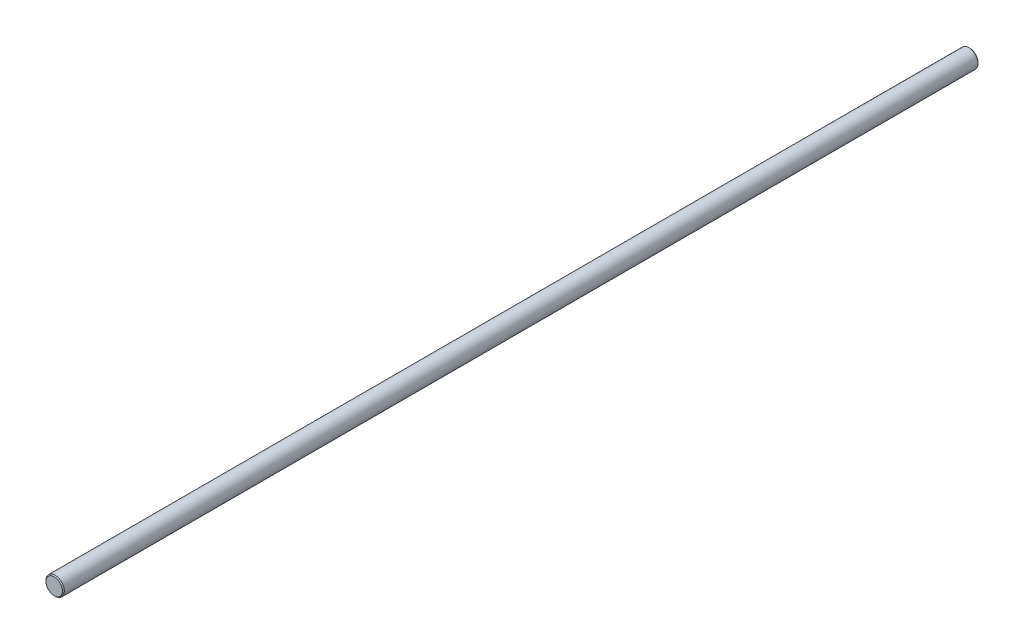
from build123d import *

# Parameters (mm, degrees)
SKETCH1_R           = 10
BOSS_EXTRUDE1_DEPTH = 1000
CHAMFER1_SIZE       = 1
SKETCH2_R           = 3
CUT_EXTRUDE1_DEPTH  = 10
LPATTERN1_COUNT     = 7
LPATTERN1_PITCH     = 150


with BuildPart() as part:
    # Sketch1 → Boss-Extrude1 (new body)
    with BuildSketch(Plane.XY):
        Circle(SKETCH1_R)
    extrude(amount=BOSS_EXTRUDE1_DEPTH)

    # Chamfer1
    chamfer1_edges = [part.edges().sort_by_distance(p)[0] for p in [
        (-10, 0, 0),
        (-10, 0, 1000),
    ]]
    chamfer(chamfer1_edges, length=CHAMFER1_SIZE)

    # Sketch2 → Cut-Extrude1 (cut)
    with BuildSketch(Plane(origin=(0, 0, 0), x_dir=(1, 0, 0), z_dir=(0, 1, 0))):
        with Locations((0, -15)):
            Circle(SKETCH2_R)
    cut_extrude1 = extrude(amount=-CUT_EXTRUDE1_DEPTH, mode=Mode.SUBTRACT)

    # LPattern1: Cut-Extrude1 ×7
    with Locations(*[(0, 0, i * LPATTERN1_PITCH) for i in range(1, LPATTERN1_COUNT)]):
        add(cut_extrude1, mode=Mode.SUBTRACT)


solid = part.part
